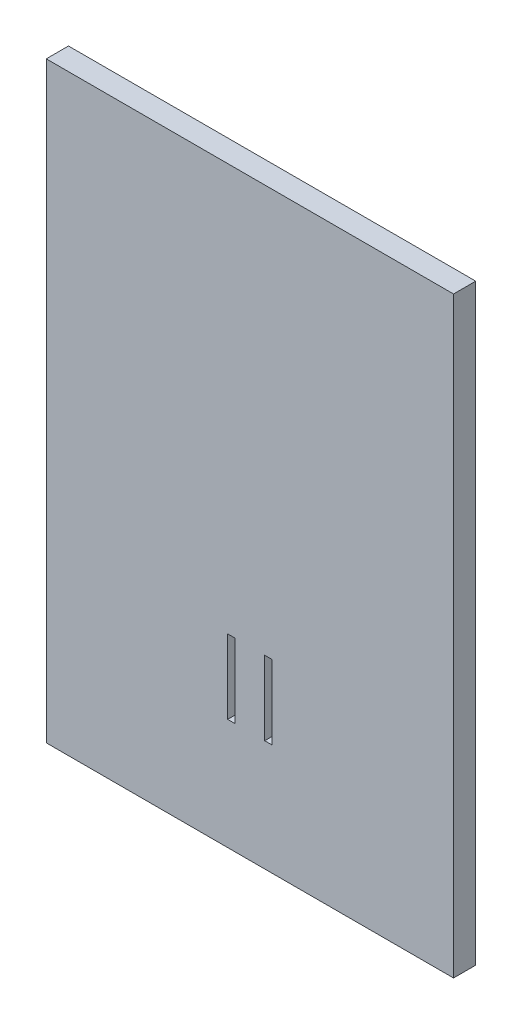
from build123d import *

# Parameters (mm, degrees)
SKETCH1_W           = 55
SKETCH1_H           = 80
SKETCH1_W_2         = 1
SKETCH1_H_2         = 10
BOSS_EXTRUDE1_DEPTH = 3


with BuildPart() as part:
    # Sketch1 → Boss-Extrude1 (new body)
    with BuildSketch(Plane.XY):
        Rectangle(SKETCH1_W, SKETCH1_H)
        with Locations((2.5, -20)):
            Rectangle(SKETCH1_W_2, SKETCH1_H_2, mode=Mode.SUBTRACT)
        with Locations((-2.5, -20)):
            Rectangle(SKETCH1_W_2, SKETCH1_H_2, mode=Mode.SUBTRACT)
    extrude(amount=BOSS_EXTRUDE1_DEPTH)


solid = part.part
